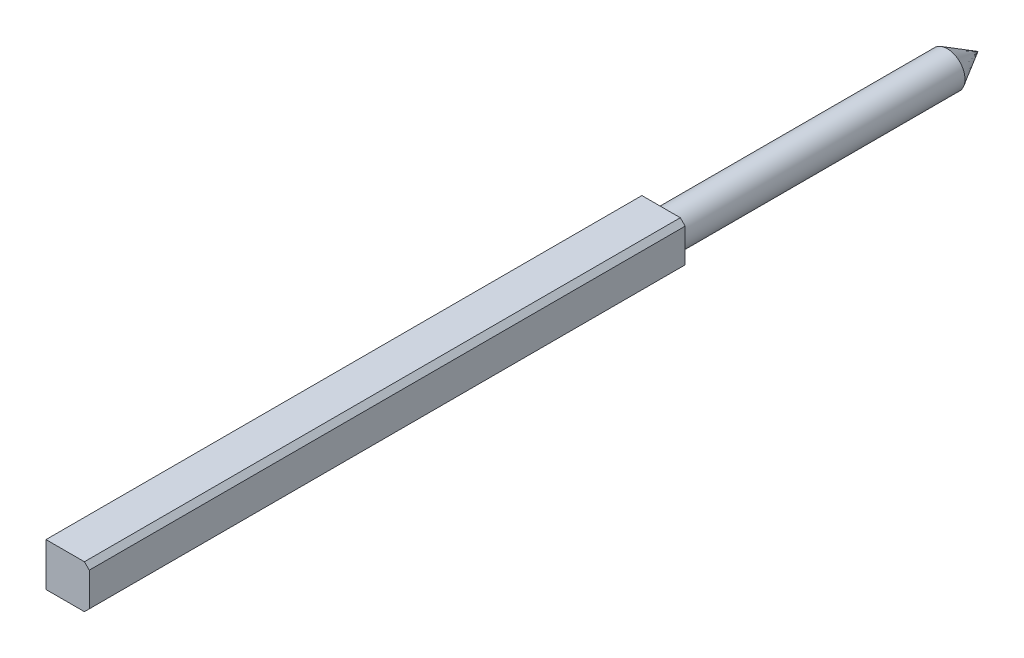
from build123d import *

# Parameters (mm, degrees)
SKETCH1_W           = 6.1
SKETCH1_H           = 6.1
BOSS_EXTRUDE1_DEPTH = 84
SKETCH1_4_R         = 2.5
BOSS_EXTRUDE2_DEPTH = 40
CHAMFER_BASE_SIZE   = 0.686


with BuildPart() as part:
    # Sketch1 → Boss-Extrude1 (new body)
    with BuildSketch(Plane.XY):
        Rectangle(SKETCH1_W, SKETCH1_H)
    extrude(amount=BOSS_EXTRUDE1_DEPTH)

    # Sketch1_4 → Boss-Extrude2 (add)
    with BuildSketch(Plane.XY):
        Circle(SKETCH1_4_R)
    extrude(amount=-BOSS_EXTRUDE2_DEPTH)

    # Boss-Extrude3 cone 1 section (through the dimple's axis) → Boss-Extrude3 (revolve)
    with BuildSketch(Plane(origin=(0, 0, -40), x_dir=(0, -1, 0), z_dir=(1, 0, 0))):
        Polygon((0, 0), (2.5, 0), (0, 4.330127019), align=None)
    revolve(axis=Axis((0, 0, -40), (0, 0, -1)))

    # chamfer_base
    chamfer_base_edges = [part.edges().sort_by_distance(p)[0] for p in [
        (3.05, -3.05, 42),
        (3.05, 3.05, 42),
    ]]
    chamfer(chamfer_base_edges, length=CHAMFER_BASE_SIZE)


solid = part.part
